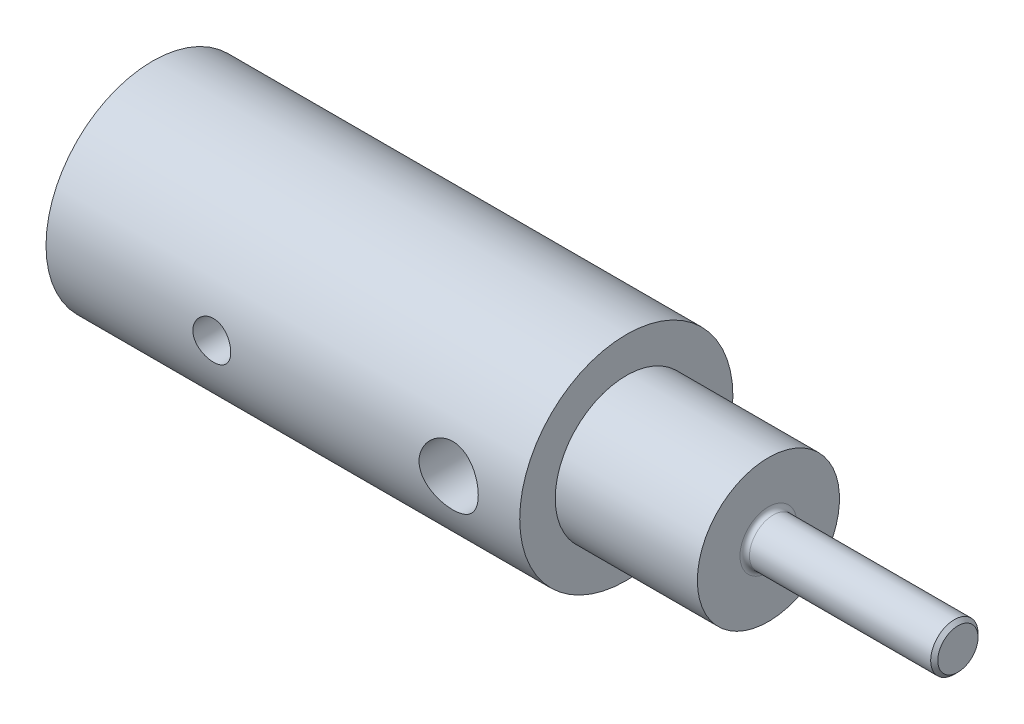
from build123d import *

# Parameters (mm, degrees)
FASE1_SIZE                           = 0.15
SKIZZE5_W                            = 0.8
SKIZZE5_H                            = 4.5
SKIZZE7_R                            = 1.25
SCHNITT_LINEAR_AUSTRAGEN2_DEPTH      = 5.50000011
SCHNITT_LINEAR_AUSTRAGEN2_DEPTH_BACK = 5.5000001
VERRUNDUNG1_R                        = 0.2


with BuildPart() as part:
    # Skizze1 → Rotation1 (revolve)
    with BuildSketch(Plane.XY):
        Polygon((0, 4.5), (0, 2), (14, 2), (15.201721238, 0), (34, 0), (34, 1), (26, 1), (26, 3), (20, 3), (20, 4.5), align=None)
    revolve(axis=Axis((0, 0, 0), (1, 0, 0)))

    # Fase1
    fase1_edges = [part.edges().sort_by_distance(p)[0] for p in [
        (34, -1, 0),
    ]]
    chamfer(fase1_edges, length=FASE1_SIZE)

    # Skizze5 → M2 Gewindebohrung1 (revolve, cut)
    with BuildSketch(Plane.YZ.offset(7)):
        with Locations((0.4, 2.25)):
            Rectangle(SKIZZE5_W, SKIZZE5_H)
    revolve(axis=Axis((7, 0, -6.35), (0, 0, 1)), mode=Mode.SUBTRACT)

    # Skizze7 → Schnitt-Linear austragen2 (cut, two sides)
    with BuildSketch(Plane.XY) as schnitt_linear_austragen2_sk:
        with Locations((17, 0)):
            Circle(SKIZZE7_R)
    extrude(amount=SCHNITT_LINEAR_AUSTRAGEN2_DEPTH, mode=Mode.SUBTRACT)
    extrude(schnitt_linear_austragen2_sk.sketch, amount=-SCHNITT_LINEAR_AUSTRAGEN2_DEPTH_BACK, mode=Mode.SUBTRACT)

    # Verrundung1
    verrundung1_edges = [part.edges().sort_by_distance(p)[0] for p in [
        (26, -1, 0),
    ]]
    fillet(verrundung1_edges, radius=VERRUNDUNG1_R)


solid = part.part
